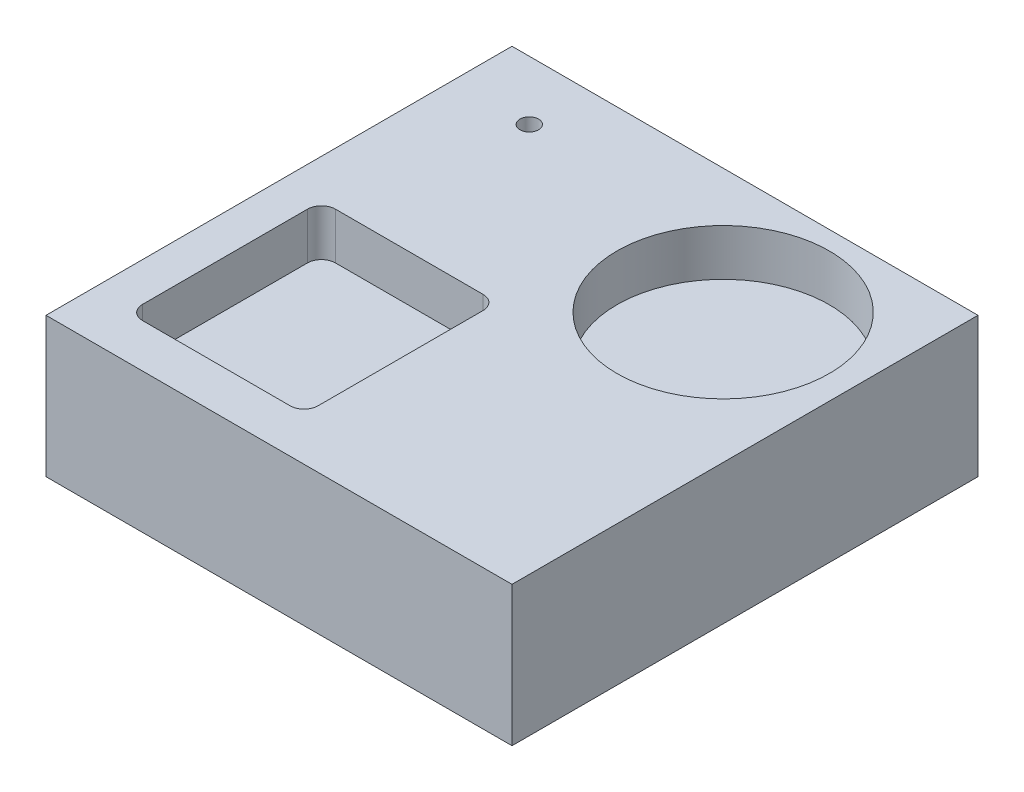
from build123d import *

# Parameters (mm, degrees)
SKETCH1_W           = 100
SKETCH1_H           = 100
BOSS_EXTRUDE1_DEPTH = 30
SKETCH5_R           = 2
CUT_EXTRUDE1_DEPTH  = 31
SKETCH7_R           = 22.78996388
SKETCH7_W           = 37.683489423
SKETCH7_H           = 41.413312703
CUT_EXTRUDE2_DEPTH  = 10
FILLET1_R           = 3


with BuildPart() as part:
    # Sketch1 → Boss-Extrude1 (new body)
    with BuildSketch(Plane(origin=(0, 0, 0), x_dir=(1, 0, 0), z_dir=(0, 1, 0))):
        with Locations((50, 50)):
            Rectangle(SKETCH1_W, SKETCH1_H)
    extrude(amount=BOSS_EXTRUDE1_DEPTH)

    # Sketch5 → Cut-Extrude1 (cut, through all)
    with BuildSketch(Plane(origin=(0, 30, 0), x_dir=(1, 0, 0), z_dir=(0, 1, 0))):
        with Locations((16.384313545, 87.323198024)):
            Circle(SKETCH5_R)
    extrude(amount=-CUT_EXTRUDE1_DEPTH, mode=Mode.SUBTRACT)

    # Sketch7 → Cut-Extrude2 (cut)
    with BuildSketch(Plane(origin=(0, 30, 0), x_dir=(1, 0, 0), z_dir=(0, 1, 0))):
        with Locations((72.084640228, 73.225170758)):
            Circle(SKETCH7_R)
        with Locations((27.16963915, 30.080771209)):
            Rectangle(SKETCH7_W, SKETCH7_H)
    extrude(amount=-CUT_EXTRUDE2_DEPTH, mode=Mode.SUBTRACT)

    # Fillet1
    fillet1_edges = [part.edges().sort_by_distance(p)[0] for p in [
        (8.327894438, 25, -9.374114858),
        (8.327894438, 25, -50.787427561),
        (46.011383861, 25, -50.787427561),
        (46.011383861, 25, -9.374114858),
    ]]
    fillet(fillet1_edges, radius=FILLET1_R)


solid = part.part
